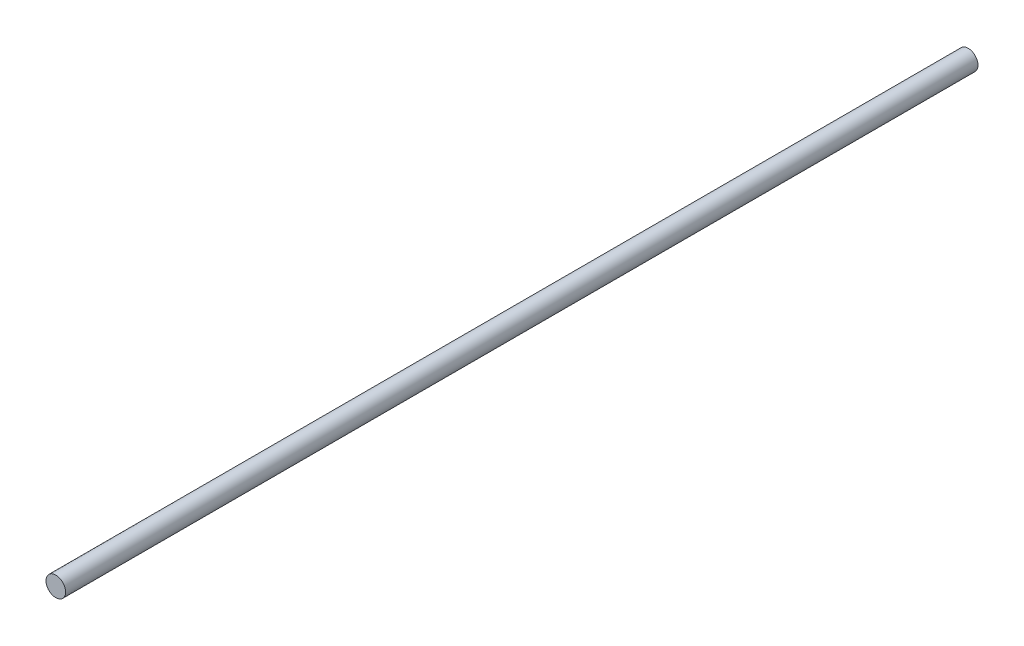
from build123d import *

# Parameters (mm, degrees)
SKETCH1_R           = 4
BOSS_EXTRUDE1_DEPTH = 372


with BuildPart() as part:
    # Sketch1 → Boss-Extrude1 (new body)
    with BuildSketch(Plane.XY):
        Circle(SKETCH1_R)
    extrude(amount=BOSS_EXTRUDE1_DEPTH)


solid = part.part
